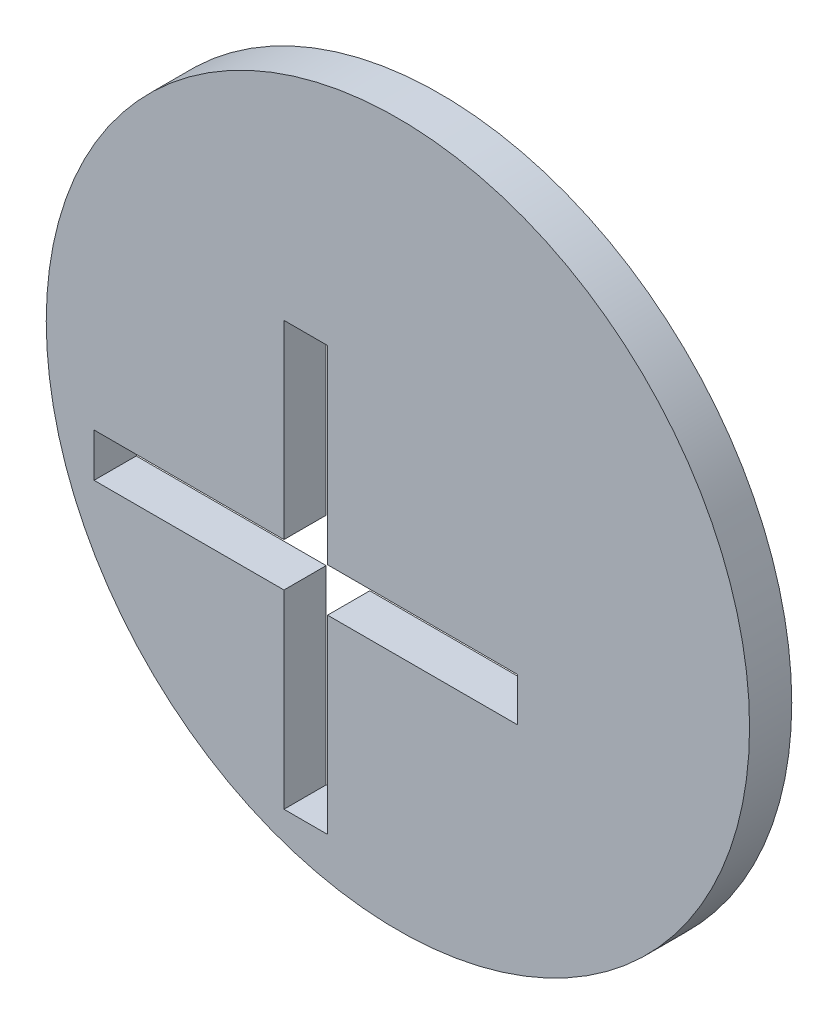
from build123d import *

# Parameters (mm, degrees)
SKETCH1_R           = 25
BOSS_EXTRUDE1_DEPTH = 1.5


with BuildPart() as part:
    # Sketch1 → Boss-Extrude1 (new body, symmetric)
    with BuildSketch(Plane.XY):
        with Locations((6.55, 6.55)):
            Circle(SKETCH1_R)
        Polygon((1.55, 1.55), (15.05, 1.55), (15.05, -1.55), (1.55, -1.55), (1.55, -15.05), (-1.55, -15.05), (-1.55, -1.55), (-15.05, -1.55), (-15.05, 1.55), (-1.55, 1.55), (-1.55, 15.05), (1.55, 15.05), align=None, mode=Mode.SUBTRACT)
    extrude(amount=BOSS_EXTRUDE1_DEPTH, both=True)


solid = part.part
